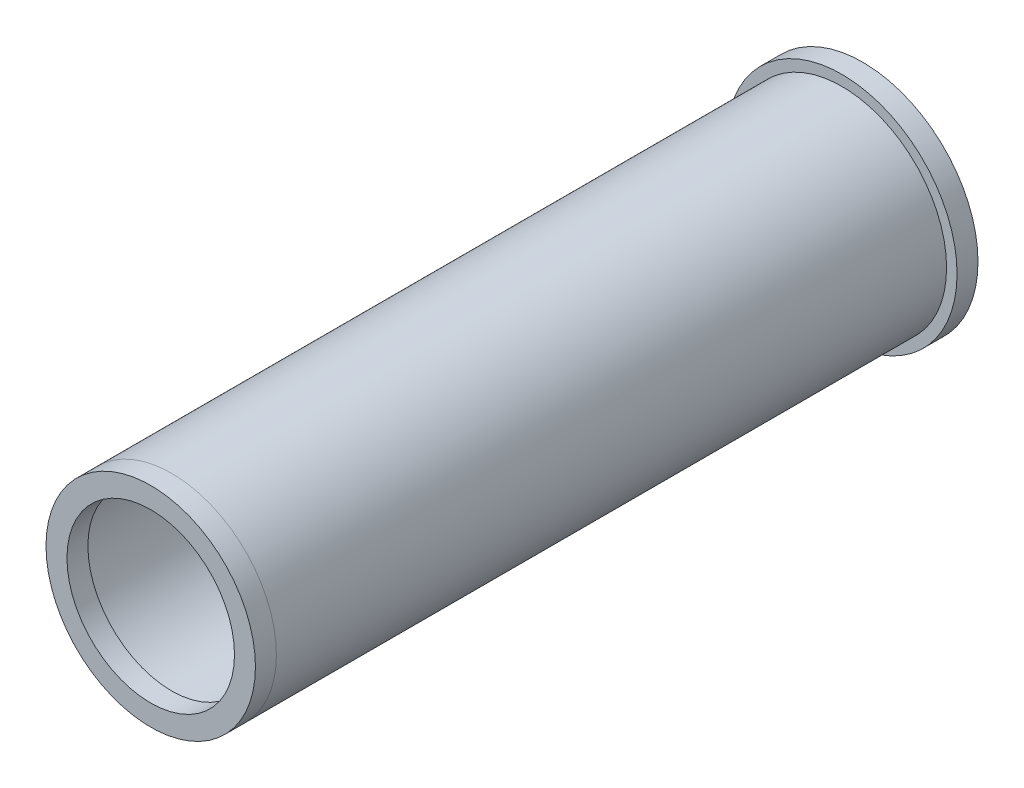
from build123d import *

# Parameters (mm, degrees)
SKETCH1_R           = 69.85
SKETCH1_R_2         = 57.15
BOSS_EXTRUDE1_DEPTH = 12.7
BOSS_EXTRUDE2_START = 406.4
SKETCH1_3_R         = 63.5
SKETCH1_3_R_2       = 57.15
BOSS_EXTRUDE2_DEPTH = 406.4
SKETCH2_R           = 63.5
SKETCH2_R_2         = 50.8
BOSS_EXTRUDE3_DEPTH = 12.7


with BuildPart() as part:
    # Sketch1 → Boss-Extrude1 (new body)
    with BuildSketch(Plane.XY):
        Circle(SKETCH1_R)
        Circle(SKETCH1_R_2, mode=Mode.SUBTRACT)
    extrude(amount=-BOSS_EXTRUDE1_DEPTH)

    # Sketch1_3 → Boss-Extrude2 (add)
    with BuildSketch(Plane.XY.offset(BOSS_EXTRUDE2_START)):
        Circle(SKETCH1_3_R)
        Circle(SKETCH1_3_R_2, mode=Mode.SUBTRACT)
    extrude(amount=-BOSS_EXTRUDE2_DEPTH)


with BuildPart() as body_2:
    # Sketch2 → Boss-Extrude3 (new body)
    with BuildSketch(Plane.XY.offset(406.4)):
        Circle(SKETCH2_R)
        Circle(SKETCH2_R_2, mode=Mode.SUBTRACT)
    extrude(amount=BOSS_EXTRUDE3_DEPTH)


solid = Compound([part.part, body_2.part])
